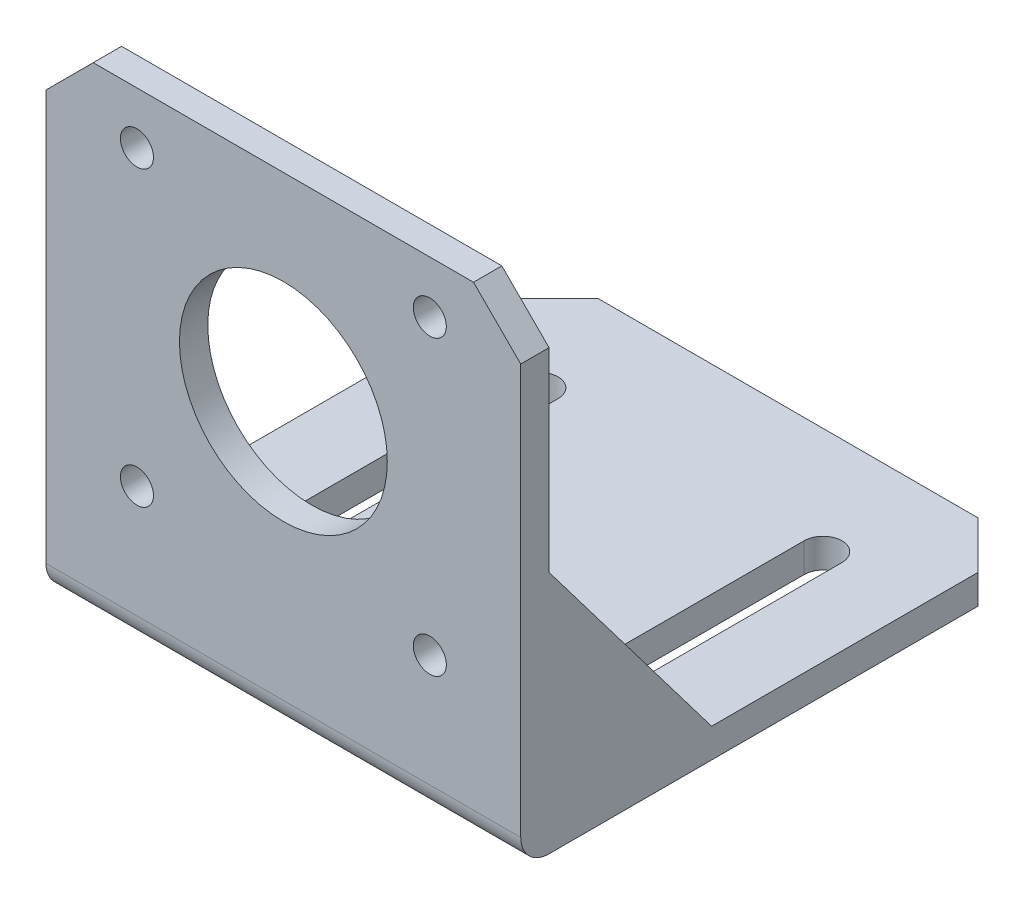
from build123d import *

# Parameters (mm, degrees)
SKETCH1_R           = 11
SKETCH1_R_2         = 1.75
BOSS_EXTRUDE1_DEPTH = 3
BOSS_EXTRUDE2_DEPTH = 3.1
BOSS_EXTRUDE3_DEPTH = 2.6
FILLET1_R           = 3
FILLET2_R           = 3


with BuildPart() as part:
    # Sketch1 → Boss-Extrude1 (new body)
    with BuildSketch(Plane.XY):
        Polygon((0, 46.4), (5, 51.4), (45.25, 51.4), (50.25, 46.4), (50.25, 0), (0, 0), align=None)
        with Locations((25.125, 30.4)):
            Circle(SKETCH1_R, mode=Mode.SUBTRACT)
        with Locations((9.625, 45.9)):
            Circle(SKETCH1_R_2, mode=Mode.SUBTRACT)
        with Locations((40.625, 45.9)):
            Circle(SKETCH1_R_2, mode=Mode.SUBTRACT)
        with Locations((40.625, 14.9)):
            Circle(SKETCH1_R_2, mode=Mode.SUBTRACT)
        with Locations((9.625, 14.9)):
            Circle(SKETCH1_R_2, mode=Mode.SUBTRACT)
    extrude(amount=BOSS_EXTRUDE1_DEPTH)

    # Sketch2 → Boss-Extrude2 (add)
    with BuildSketch(Plane.XZ):
        Polygon((0, 3), (50.25, 3), (50.25, -45.4), (45.25, -50.4), (5, -50.4), (0, -45.4), align=None)
        with BuildLine():
            Line((42.15, -9.1), (42.15, -39.1))
            ThreePointArc((42.15, -39.1), (40.15, -41.1), (38.15, -39.1))
            Line((38.15, -39.1), (38.15, -9.1))
            ThreePointArc((38.15, -9.1), (40.15, -7.1), (42.15, -9.1))
        make_face(mode=Mode.SUBTRACT)
        with BuildLine():
            Line((8.1, -9.1), (8.1, -39.1))
            ThreePointArc((8.1, -39.1), (10.1, -41.1), (12.1, -39.1))
            Line((12.1, -39.1), (12.1, -9.1))
            ThreePointArc((12.1, -9.1), (10.1, -7.1), (8.1, -9.1))
        make_face(mode=Mode.SUBTRACT)
    extrude(amount=-BOSS_EXTRUDE2_DEPTH)

    # Sketch3 → Boss-Extrude3 (add)
    with BuildSketch(Plane.ZY):
        Polygon((0, 25.8), (-17.2, 3.1), (-17.2, 0), (3, 0), (3, 25.8), align=None)
    boss_extrude3 = extrude(amount=-BOSS_EXTRUDE3_DEPTH)

    # Mirror1: Boss-Extrude3 across plane
    add(boss_extrude3.mirror(Plane.ZY.offset(-25.125)))

    # Fillet1
    fillet1_edges = [part.edges().sort_by_distance(p)[0] for p in [
        (25.125, 0, 3),
    ]]
    fillet(fillet1_edges, radius=FILLET1_R)

    # Fillet2
    fillet2_edges = [part.edges().sort_by_distance(p)[0] for p in [
        (25.125, 3.1, 0),
    ]]
    fillet(fillet2_edges, radius=FILLET2_R)


solid = part.part
